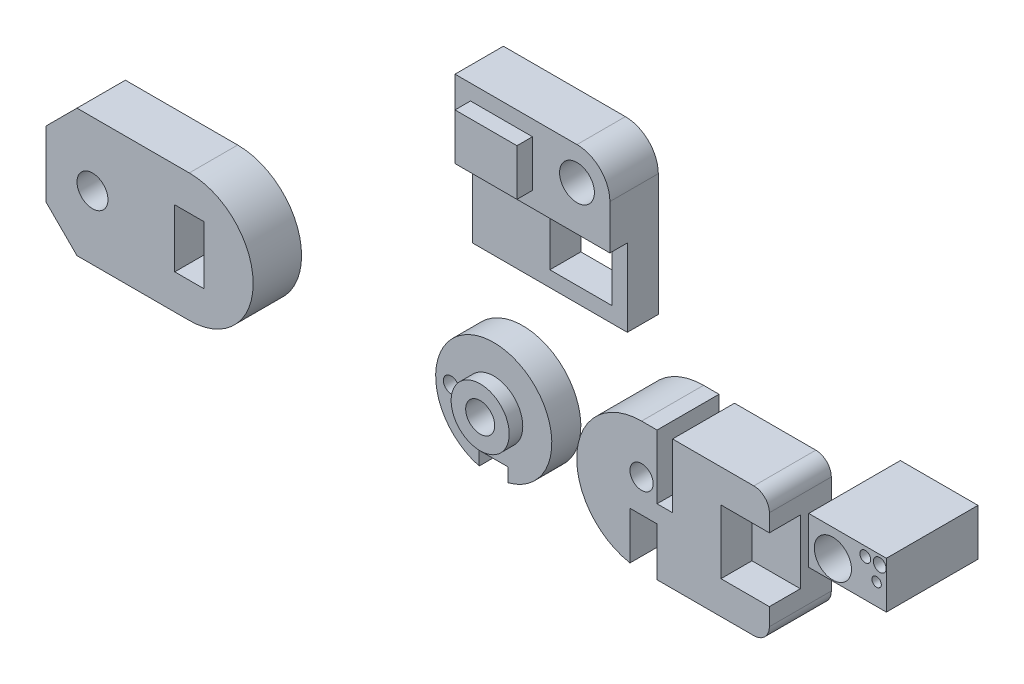
from build123d import *

# Parameters (mm, degrees)
CROQUIS3_W               = 32
CROQUIS3_H               = 24
CROQUIS3_R               = 9
SALIENTE_EXTRUIR4_DEPTH  = 25
CROQUIS3_5_W             = 80
CROQUIS3_5_H             = 40
CROQUIS3_5_W_2           = 32
CROQUIS3_5_H_2           = 24
SALIENTE_EXTRUIR5_DEPTH  = 33
CROQUIS5_W               = 80
CROQUIS5_H               = 40
CORTAR_EXTRUIR1_DEPTH    = 17
CROQUIS3_11_W            = 32
CROQUIS3_11_H            = 24
CORTAR_EXTRUIR2_DEPTH    = 30
SALIENTE_EXTRUIR6_DEPTH  = 15
CROQUIS8_4_R             = 15
SALIENTE_EXTRUIR7_DEPTH  = 22
CROQUIS8_6_R             = 4
CORTAR_EXTRUIR5_DEPTH    = 48
CROQUIS8_7_R             = 7.5
CORTAR_EXTRUIR6_DEPTH    = 48
CROQUIS9_R               = 6
SALIENTE_EXTRUIR8_DEPTH  = 32
CROQUIS9_3_W             = 25
CROQUIS9_3_H             = 33
SALIENTE_EXTRUIR9_DEPTH  = 16
SALIENTE_EXTRUIR11_DEPTH = 25
CROQUIS10_4_W            = 15
CROQUIS10_4_H            = 30
CORTAR_EXTRUIR7_DEPTH    = 25
CROQUIS10_5_R            = 8
CORTAR_EXTRUIR8_DEPTH    = 25
CORTAR_EXTRUIR9_DEPTH    = 8.333333333
CROQUIS14_W              = 40.09551918
CROQUIS14_H              = 24.100376272
CROQUIS14_R              = 3.314232671
CROQUIS14_R_2            = 9.592276939
CROQUIS14_R_3            = 2.417801169
CROQUIS14_R_4            = 2.788674417
SALIENTE_EXTRUIR12_DEPTH = 47.333333333


with BuildPart() as part:
    # Croquis3 → Saliente-Extruir4 (new body)
    with BuildSketch(Plane.XY):
        with BuildLine():
            Line((113, 70), (50, 70))
            Line((50, 70), (50, 30))
            Line((50, 30), (130, 30))
            Line((130, 30), (130, 53))
            ThreePointArc((130, 53), (125.02081528, 65.02081528), (113, 70))
        make_face()
        with Locations((74, 50)):
            Rectangle(CROQUIS3_W, CROQUIS3_H, mode=Mode.SUBTRACT)
        with Locations((113, 53)):
            Circle(CROQUIS3_R, mode=Mode.SUBTRACT)
    extrude(amount=SALIENTE_EXTRUIR4_DEPTH)

    # Croquis3_5 → Saliente-Extruir5 (add)
    with BuildSketch(Plane.XY):
        with Locations((90, 10)):
            Rectangle(CROQUIS3_5_W, CROQUIS3_5_H)
        with Locations((74, 50)):
            Rectangle(CROQUIS3_5_W_2, CROQUIS3_5_H_2)
    extrude(amount=SALIENTE_EXTRUIR5_DEPTH)

    # Croquis5 → Cortar-Extruir1 (cut)
    with BuildSketch(Plane.XY.offset(33)):
        with Locations((90, 10)):
            Rectangle(CROQUIS5_W, CROQUIS5_H)
    extrude(amount=-CORTAR_EXTRUIR1_DEPTH, mode=Mode.SUBTRACT)

    # Croquis3_11 → Cortar-Extruir2 (cut)
    with BuildSketch(Plane.XY):
        with Locations((106, 10)):
            Rectangle(CROQUIS3_11_W, CROQUIS3_11_H)
    extrude(amount=CORTAR_EXTRUIR2_DEPTH, mode=Mode.SUBTRACT)


with BuildPart() as body_2:
    # Croquis8 → Saliente-Extruir6 (new body)
    with BuildSketch(Plane.XY):
        with BuildLine():
            Line((52.5, -102), (52.5, -109.047375097))
            ThreePointArc((52.5, -109.047375097), (60, -50), (67.5, -109.047375097))
            Line((67.5, -109.047375097), (67.5, -102))
            Line((67.5, -102), (52.5, -102))
        make_face()
    extrude(amount=SALIENTE_EXTRUIR6_DEPTH)

    # Croquis8_4 → Saliente-Extruir7 (add)
    with BuildSketch(Plane.XY):
        with Locations((60, -80)):
            Circle(CROQUIS8_4_R)
    extrude(amount=SALIENTE_EXTRUIR7_DEPTH)

    # Croquis8_6 → Cortar-Extruir5 (cut)
    with BuildSketch(Plane.XY):
        with Locations((38, -80)):
            Circle(CROQUIS8_6_R)
    extrude(amount=CORTAR_EXTRUIR5_DEPTH, mode=Mode.SUBTRACT)

    # Croquis8_7 → Cortar-Extruir6 (cut)
    with BuildSketch(Plane.XY):
        with Locations((60, -80)):
            Circle(CROQUIS8_7_R)
    extrude(amount=CORTAR_EXTRUIR6_DEPTH, mode=Mode.SUBTRACT)


with BuildPart() as body_3:
    # Croquis9 → Saliente-Extruir8 (new body)
    with BuildSketch(Plane.XY):
        with BuildLine():
            Line((161.364777361, -63), (161.364777361, -30))
            Line((161.364777361, -30), (153.364774009, -30))
            ThreePointArc((153.364774009, -30), (120, -60.493069396), (147.375187785, -96.460200496))
            Line((147.375187785, -96.460200496), (147.375187785, -72))
            Line((147.375187785, -72), (161.364777361, -72))
            Line((161.364777361, -72), (161.364777361, -97))
            Line((161.364777361, -97), (211.364777361, -97))
            ThreePointArc((211.364777361, -97), (217.02163161, -94.656854249), (219.364777361, -89))
            Line((219.364777361, -89), (219.364777361, -80))
            Line((219.364777361, -80), (194.364777361, -80))
            Line((194.364777361, -80), (194.364777361, -47))
            Line((194.364777361, -47), (219.364777361, -47))
            Line((219.364777361, -47), (219.364777361, -38))
            ThreePointArc((219.364777361, -38), (217.02163161, -32.343145751), (211.364777361, -30))
            Line((211.364777361, -30), (169.364777361, -30))
            Line((169.364777361, -30), (169.364777361, -63))
            Line((169.364777361, -63), (161.364777361, -63))
        make_face()
        with Locations((153.364777361, -55)):
            Circle(CROQUIS9_R, mode=Mode.SUBTRACT)
    extrude(amount=SALIENTE_EXTRUIR8_DEPTH)

    # Croquis9_3 → Saliente-Extruir9 (add)
    with BuildSketch(Plane.XY):
        with Locations((206.864777361, -63.5)):
            Rectangle(CROQUIS9_3_W, CROQUIS9_3_H)
    extrude(amount=SALIENTE_EXTRUIR9_DEPTH)


with BuildPart() as body_4:
    # Croquis10 → Saliente-Extruir11 (new body)
    with BuildSketch(Plane.XY):
        with BuildLine():
            Line((-161.257005587, -58.81683994), (-161.257005587, -92.81683994))
            Line((-161.257005587, -92.81683994), (-145.257005587, -108.81683994))
            Line((-145.257005587, -108.81683994), (-87.257005587, -108.81683994))
            ThreePointArc((-87.257005587, -108.81683994), (-54.257005587, -75.81683994), (-87.257005587, -42.81683994))
            Line((-87.257005587, -42.81683994), (-145.257005587, -42.81683994))
            Line((-145.257005587, -42.81683994), (-161.257005587, -58.81683994))
        make_face()
    extrude(amount=SALIENTE_EXTRUIR11_DEPTH)

    # Croquis10_4 → Cortar-Extruir7 (cut)
    with BuildSketch(Plane.XY):
        with Locations((-87.257005587, -75.81683994)):
            Rectangle(CROQUIS10_4_W, CROQUIS10_4_H)
    extrude(amount=CORTAR_EXTRUIR7_DEPTH, mode=Mode.SUBTRACT)

    # Croquis10_5 → Cortar-Extruir8 (cut)
    with BuildSketch(Plane.XY):
        with Locations((-137.257005587, -75.81683994)):
            Circle(CROQUIS10_5_R)
    extrude(amount=CORTAR_EXTRUIR8_DEPTH, mode=Mode.SUBTRACT)

    # Croquis13 → Cortar-Extruir9 (cut)
    with BuildSketch(Plane(origin=(0, 0, 0), x_dir=(-1, 0, 0), z_dir=(0, 0, -1))):
        with BuildLine():
            Line((161.257005587, -58.81683994), (137.257005587, -58.81683994))
            ThreePointArc((137.257005587, -58.81683994), (120.257005587, -75.81683994), (137.257005587, -92.81683994))
            Line((137.257005587, -92.81683994), (161.257005587, -92.81683994))
            Line((161.257005587, -92.81683994), (175.725705877, -74.246739019))
            Line((175.725705877, -74.246739019), (161.257005587, -58.81683994))
        make_face()
    extrude(amount=-CORTAR_EXTRUIR9_DEPTH, mode=Mode.SUBTRACT)


with BuildPart() as body_5:
    # Croquis14 → Saliente-Extruir12 (new body)
    with BuildSketch(Plane.XY):
        with Locations((275.083226021, -24.863179811)):
            Rectangle(CROQUIS14_W, CROQUIS14_H)
        with Locations((291.713457486, -17.498948227)):
            Circle(CROQUIS14_R, mode=Mode.SUBTRACT)
        with Locations((267.511415727, -26.7898702)):
            Circle(CROQUIS14_R_2, mode=Mode.SUBTRACT)
        with Locations((290.093853848, -25.908331949)):
            Circle(CROQUIS14_R_3, mode=Mode.SUBTRACT)
        with Locations((284.227163487, -17.498948227)):
            Circle(CROQUIS14_R_4, mode=Mode.SUBTRACT)
    extrude(amount=SALIENTE_EXTRUIR12_DEPTH)


solid = Compound([part.part, body_2.part, body_3.part, body_4.part, body_5.part])
